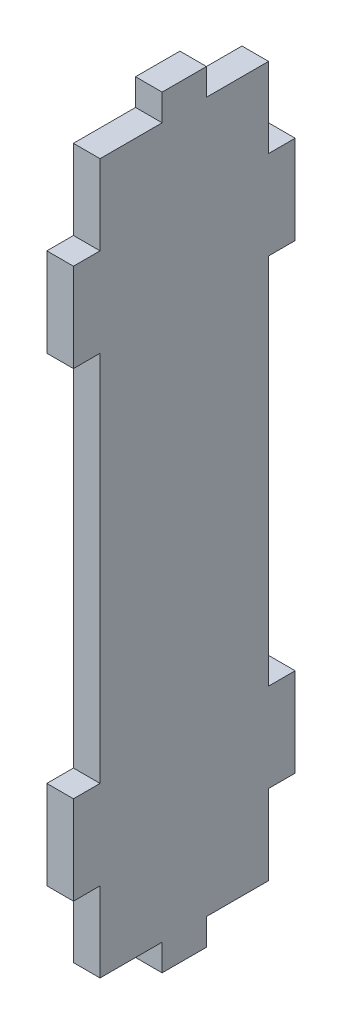
from build123d import *

# Parameters (mm, degrees)
SKETCH_1_W          = 25
SKETCH_1_H          = 86
EXTRUDE_2_DEPTH     = 3
SKETCH_4_W          = 3
SKETCH_4_H          = 12
SKETCH_4_H_2        = 42
CUT_EXTRUDE_1_DEPTH = 4
SKETCH_5_W          = 7
SKETCH_5_H          = 3
CUT_EXTRUDE_2_DEPTH = 4


with BuildPart() as part:
    # 스케치1 → 보스-돌출2 (new body)
    with BuildSketch(Plane(origin=(0, 0, 0), x_dir=(0, 0, -1), z_dir=(1, 0, 0))):
        with Locations((12.5, 43)):
            Rectangle(SKETCH_1_W, SKETCH_1_H)
    extrude(amount=EXTRUDE_2_DEPTH)

    # 스케치4 → 컷-돌출1 (cut, through all)
    with BuildSketch(Plane(origin=(3, 0, 0), x_dir=(0, 0, -1), z_dir=(1, 0, 0))):
        with Locations((1.5, 80)):
            Rectangle(SKETCH_4_W, SKETCH_4_H)
        with Locations((23.5, 80)):
            Rectangle(SKETCH_4_W, SKETCH_4_H)
        with Locations((23.5, 6)):
            Rectangle(SKETCH_4_W, SKETCH_4_H)
        with Locations((1.5, 6)):
            Rectangle(SKETCH_4_W, SKETCH_4_H)
        with Locations((1.5, 43)):
            Rectangle(SKETCH_4_W, SKETCH_4_H_2)
        with Locations((23.5, 43)):
            Rectangle(SKETCH_4_W, SKETCH_4_H_2)
    extrude(amount=-CUT_EXTRUDE_1_DEPTH, mode=Mode.SUBTRACT)

    # 스케치5 → 컷-돌출2 (cut, through all)
    with BuildSketch(Plane(origin=(3, 0, 0), x_dir=(0, 0, -1), z_dir=(1, 0, 0))):
        with Locations((6.5, 84.5)):
            Rectangle(SKETCH_5_W, SKETCH_5_H)
        with Locations((18.5, 84.5)):
            Rectangle(SKETCH_5_W, SKETCH_5_H)
        with Locations((6.5, 1.5)):
            Rectangle(SKETCH_5_W, SKETCH_5_H)
        with Locations((18.5, 1.5)):
            Rectangle(SKETCH_5_W, SKETCH_5_H)
    extrude(amount=-CUT_EXTRUDE_2_DEPTH, mode=Mode.SUBTRACT)


solid = part.part
